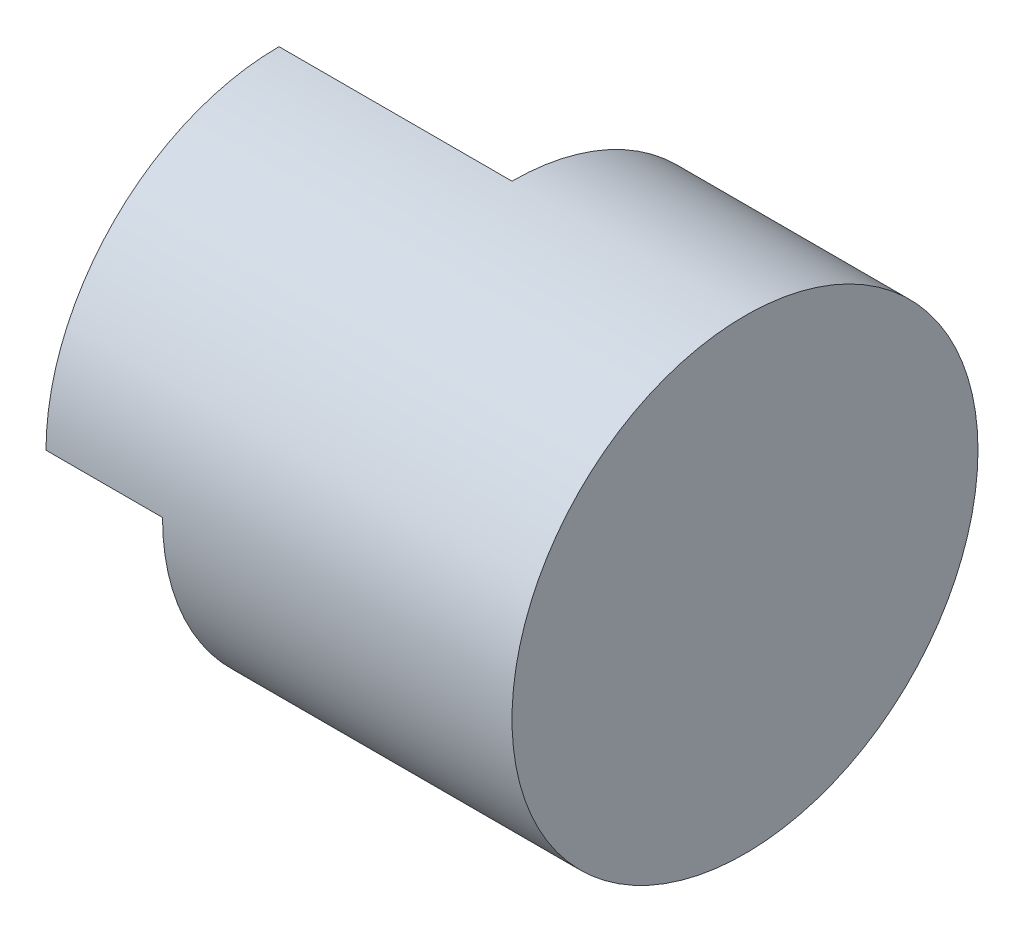
from build123d import *

# Parameters (mm, degrees)
SKETCH1_R           = 2
BOSS_EXTRUDE1_DEPTH = 2
SKETCH2_W           = 2
SKETCH2_H           = 2
CUT_EXTRUDE1_DEPTH  = 4
SKETCH3_W           = 4.29522536
SKETCH3_H           = 2.132813924
CUT_EXTRUDE2_DEPTH  = 1


with BuildPart() as part:
    # Sketch1 → Boss-Extrude1 (new body, symmetric)
    with BuildSketch(Plane(origin=(0, 0, 0), x_dir=(0, 0, -1), z_dir=(1, 0, 0))):
        Circle(SKETCH1_R)
    extrude(amount=BOSS_EXTRUDE1_DEPTH, both=True)

    # Sketch2 → Cut-Extrude1 (cut)
    with BuildSketch(Plane.XY):
        with Locations((-1, 1)):
            Rectangle(SKETCH2_W, SKETCH2_H)
    extrude(amount=-CUT_EXTRUDE1_DEPTH, mode=Mode.SUBTRACT)

    # Sketch3 → Cut-Extrude2 (cut)
    with BuildSketch(Plane.ZY.offset(2)):
        with Locations((0.14761268, -1.066406962)):
            Rectangle(SKETCH3_W, SKETCH3_H)
    extrude(amount=-CUT_EXTRUDE2_DEPTH, mode=Mode.SUBTRACT)


solid = part.part
